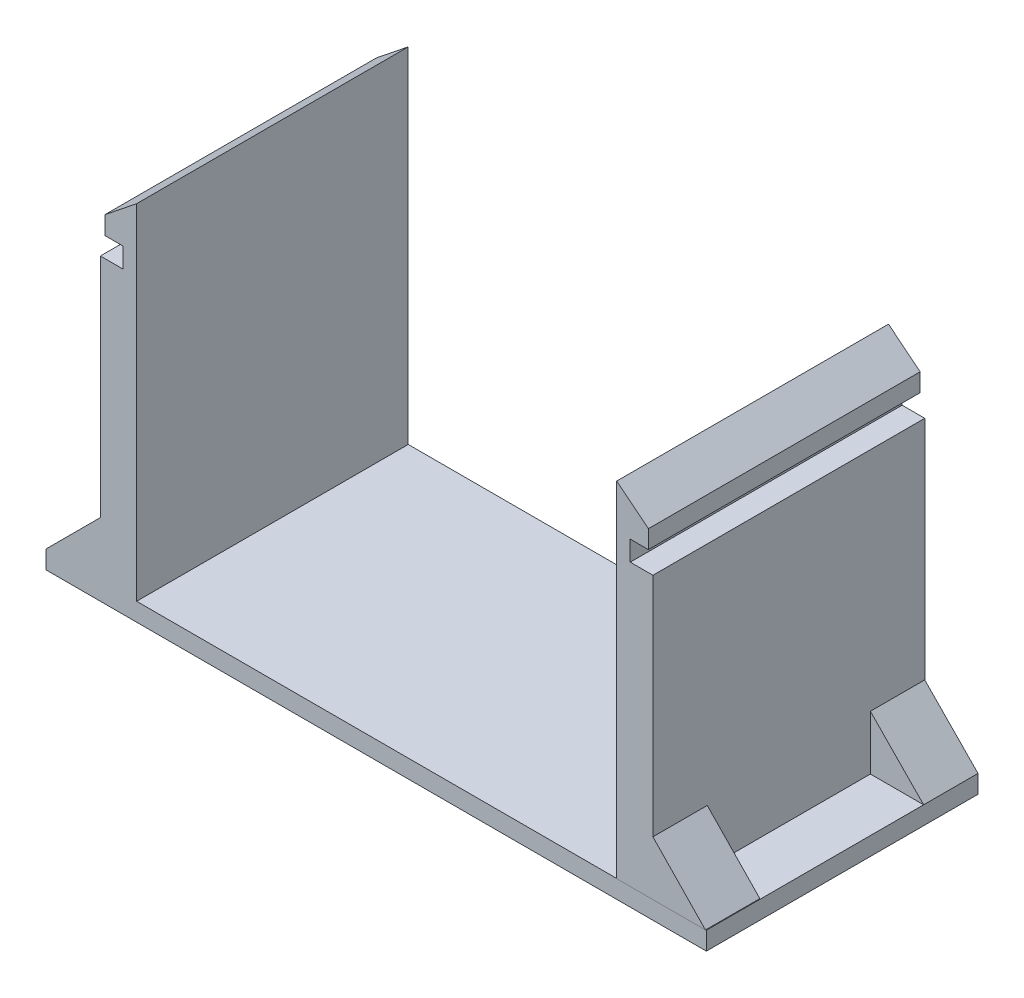
from build123d import *

# Parameters (mm, degrees)
SKETCH2_W             = 4
SKETCH2_H             = 29.975509742
BOSS_EXTRUDE1_DEPTH   = 38
BOSS_EXTRUDE1_2_DEPTH = 38
SKETCH3_W             = 72.876339672
SKETCH3_H             = 29.975509742
BOSS_EXTRUDE3_DEPTH   = 2
BOSS_EXTRUDE4_DEPTH   = 6
BOSS_EXTRUDE5_DEPTH   = 6
BOSS_EXTRUDE7_DEPTH   = 6
BOSS_EXTRUDE8_DEPTH   = 6
SKETCH17_W            = 32.717324733
SKETCH17_H            = 7
CUT_EXTRUDE9_DEPTH    = 0.5
SKETCH18_W            = 40.099699831
SKETCH18_H            = 2.2
CUT_EXTRUDE10_DEPTH   = 2
CUT_EXTRUDE11_DEPTH   = 31
SKETCH20_W            = 49.216753152
SKETCH20_H            = 10.950019834
CUT_EXTRUDE12_DEPTH   = 0.5
SKETCH21_W            = 42.54396611
SKETCH21_H            = 2.2
CUT_EXTRUDE13_DEPTH   = 2
CUT_EXTRUDE14_DEPTH   = 30.975509742


with BuildPart() as part:
    # Sketch2 → Boss-Extrude1 (new body)
    with BuildSketch(Plane(origin=(0, 0, 0), x_dir=(1, 0, 0), z_dir=(0, 1, 0))):
        with Locations((-22.117643943, -3.05661445)):
            Rectangle(SKETCH2_W, SKETCH2_H)
    extrude(amount=BOSS_EXTRUDE1_DEPTH)



with BuildPart() as body_2:
    # Sketch2 → Boss-Extrude1 2 (new body)
    with BuildSketch(Plane(origin=(0, 0, 0), x_dir=(1, 0, 0), z_dir=(0, 1, 0))):
        Polygon((36.882356057, 11.931140421), (35.682356057, 11.931140421), (32.882356057, 11.931140421), (32.882356057, -18.068859579), (36.882356057, -18.068859579), align=None)
    extrude(amount=BOSS_EXTRUDE1_2_DEPTH)


with BuildPart() as part_1:
    add(part.part)

    add(body_2.part)  # Boss-Extrude3 merges body 2
    # Sketch3 → Boss-Extrude3 (add)
    with BuildSketch(Plane(origin=(0, 0, 0), x_dir=(1, 0, 0), z_dir=(0, 1, 0))):
        with Locations((6.320525893, -3.05661445)):
            Rectangle(SKETCH3_W, SKETCH3_H)
    extrude(amount=-BOSS_EXTRUDE3_DEPTH)

    # Sketch6 → Boss-Extrude4 (add)
    with BuildSketch(Plane.XY.offset(18.068859579)):
        Polygon((36.882356057, 6), (36.882356057, 0), (42.682356057, 0), align=None)
    extrude(amount=-BOSS_EXTRUDE4_DEPTH)

    # Sketch7 → Boss-Extrude5 (add)
    with BuildSketch(Plane(origin=(0, 0, -11.931140421), x_dir=(-1, 0, 0), z_dir=(0, 0, -1))):
        Polygon((-42.758695729, 0), (-36.882356057, 6), (-36.882356057, 0), align=None)
    extrude(amount=-BOSS_EXTRUDE5_DEPTH)

    # Sketch9 → Boss-Extrude7 (add)
    with BuildSketch(Plane.XY.offset(18.044369321)):
        Polygon((-24.117643943, 6), (-30.117643943, 0), (-24.117643943, 0), align=None)
    extrude(amount=-BOSS_EXTRUDE7_DEPTH)

    # Sketch8 → Boss-Extrude8 (add)
    with BuildSketch(Plane(origin=(0, 0, -11.931140421), x_dir=(-1, 0, 0), z_dir=(0, 0, -1))):
        Polygon((24.117643943, 6), (24.117643943, 0), (30.117643943, 0), align=None)
    extrude(amount=-BOSS_EXTRUDE8_DEPTH)

    # Sketch17 → Cut-Extrude9 (cut)
    with BuildSketch(Plane(origin=(36.882356057, 0, 0), x_dir=(0, 0, -1), z_dir=(1, 0, 0))):
        with Locations((-4.427521945, 34.5)):
            Rectangle(SKETCH17_W, SKETCH17_H)
    extrude(amount=-CUT_EXTRUDE9_DEPTH, mode=Mode.SUBTRACT)

    # Sketch18 → Cut-Extrude10 (cut)
    with BuildSketch(Plane(origin=(36.382356057, 0, 0), x_dir=(0, 0, -1), z_dir=(1, 0, 0))):
        with Locations((1.980990336, 32.1)):
            Rectangle(SKETCH18_W, SKETCH18_H)
    extrude(amount=-CUT_EXTRUDE10_DEPTH, mode=Mode.SUBTRACT)

    # Sketch19 → Cut-Extrude11 (cut, through all)
    with BuildSketch(Plane.XY.offset(18.068859579)):
        Polygon((36.382356057, 35.2), (32.882356057, 38), (30.81845706, 44.907759877), (43.465809669, 41.162121973), align=None)
    extrude(amount=-CUT_EXTRUDE11_DEPTH, mode=Mode.SUBTRACT)

    # Sketch20 → Cut-Extrude12 (cut)
    with BuildSketch(Plane.ZY.offset(24.117643943)):
        with Locations((-6.564007255, 36.475009917)):
            Rectangle(SKETCH20_W, SKETCH20_H)
    extrude(amount=-CUT_EXTRUDE12_DEPTH, mode=Mode.SUBTRACT)

    # Sketch21 → Cut-Extrude13 (cut)
    with BuildSketch(Plane.ZY.offset(23.617643943)):
        with Locations((-3.227613734, 32.1)):
            Rectangle(SKETCH21_W, SKETCH21_H)
    extrude(amount=-CUT_EXTRUDE13_DEPTH, mode=Mode.SUBTRACT)

    # Sketch22 → Cut-Extrude14 (cut, through all)
    with BuildSketch(Plane.XY.offset(18.044369321)):
        Polygon((-23.617643943, 35.2), (-20.117643943, 38), (-17.308564487, 46.700014394), (-43.949503764, 46.700014394), (-33.84948937, 36.6), align=None)
    extrude(amount=-CUT_EXTRUDE14_DEPTH, mode=Mode.SUBTRACT)


solid = part_1.part
